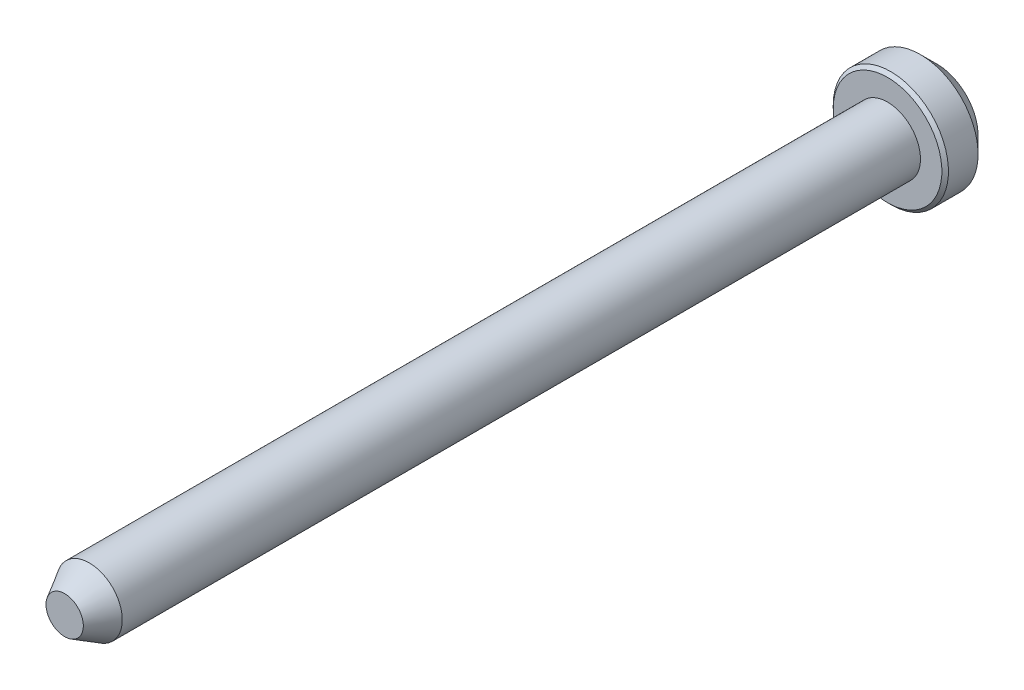
from build123d import *

# Parameters (mm, degrees)
CHAMFER1_SIZE = 0.2


with BuildPart() as part:
    # Sketch1 → Revolve1 (revolve)
    with BuildSketch(Plane(origin=(0, 0, 0), x_dir=(1, 0, 0), z_dir=(0, 1, 0))):
        Polygon((0, 0), (0, 53), (2.5, 53), (3.5, 52), (3.5, 50), (2, 50), (2, 1.5), (1.133974596, 0), align=None)
    revolve(axis=Axis((0, 0, 0), (0, 0, 1)))

    # Chamfer1
    chamfer1_edges = [part.edges().sort_by_distance(p)[0] for p in [
        (-3.5, 0, -50),
    ]]
    chamfer(chamfer1_edges, length=CHAMFER1_SIZE)


solid = part.part
